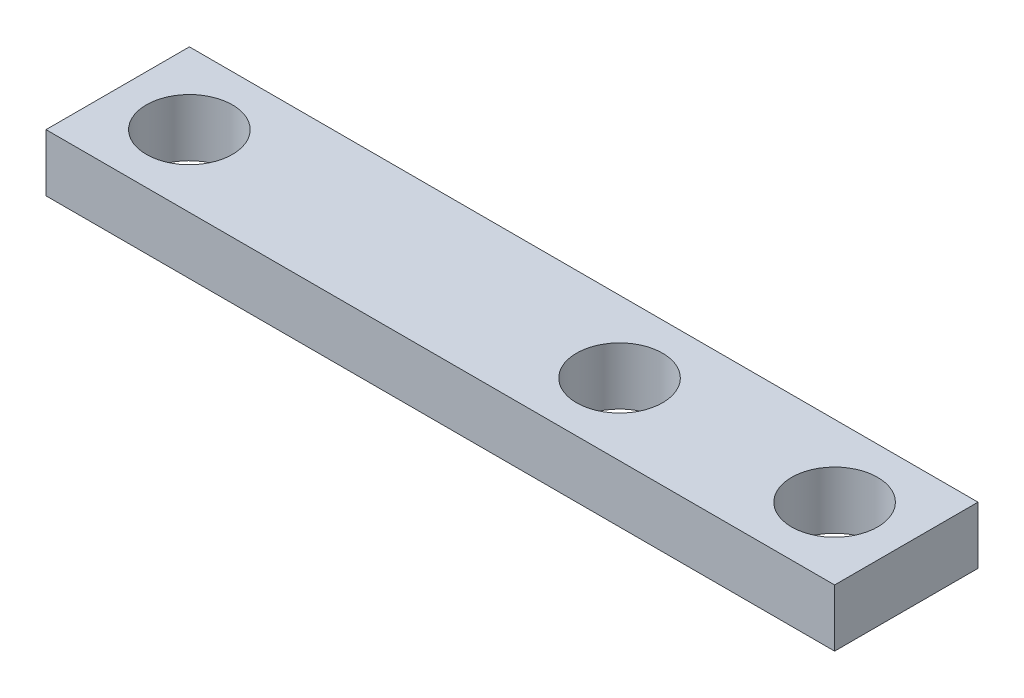
from build123d import *

# Parameters (mm, degrees)
SKETCH1_W           = 34.925
SKETCH1_H           = 6.35
SKETCH1_R           = 1.905
BOSS_EXTRUDE1_DEPTH = 2.54


with BuildPart() as part:
    # Sketch1 → Boss-Extrude1 (new body)
    with BuildSketch(Plane(origin=(0, 0, 0), x_dir=(1, 0, 0), z_dir=(0, 1, 0))):
        with Locations((-4.7625, 0)):
            Rectangle(SKETCH1_W, SKETCH1_H)
        with Locations((-19.05, 0)):
            Circle(SKETCH1_R, mode=Mode.SUBTRACT)
        with Locations((9.525, 0)):
            Circle(SKETCH1_R, mode=Mode.SUBTRACT)
        Circle(SKETCH1_R, mode=Mode.SUBTRACT)
    extrude(amount=BOSS_EXTRUDE1_DEPTH)


solid = part.part
